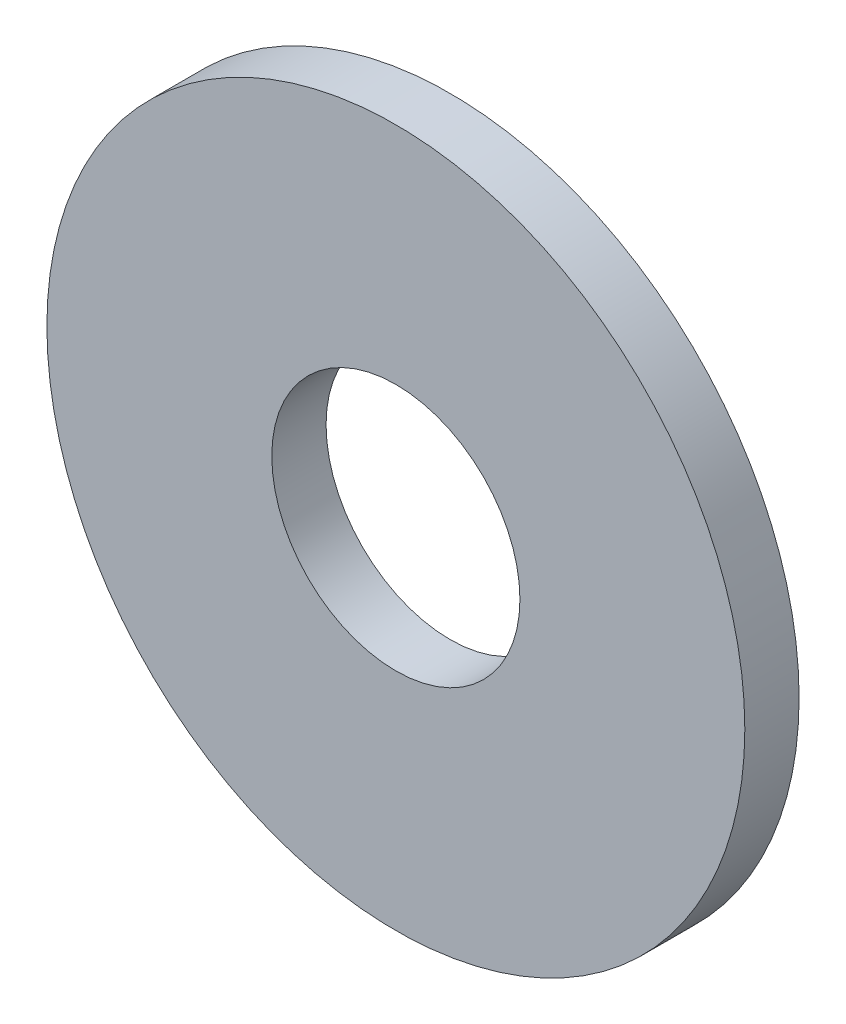
from build123d import *

# Parameters (mm, degrees)
SKETCH1_R      = 4.5
SKETCH1_R_2    = 1.6
EXTRUDE1_DEPTH = 0.7


with BuildPart() as part:
    # Sketch1 → Extrude1 (new body)
    with BuildSketch(Plane.XY):
        Circle(SKETCH1_R)
        Circle(SKETCH1_R_2, mode=Mode.SUBTRACT)
    extrude(amount=-EXTRUDE1_DEPTH)


solid = part.part
